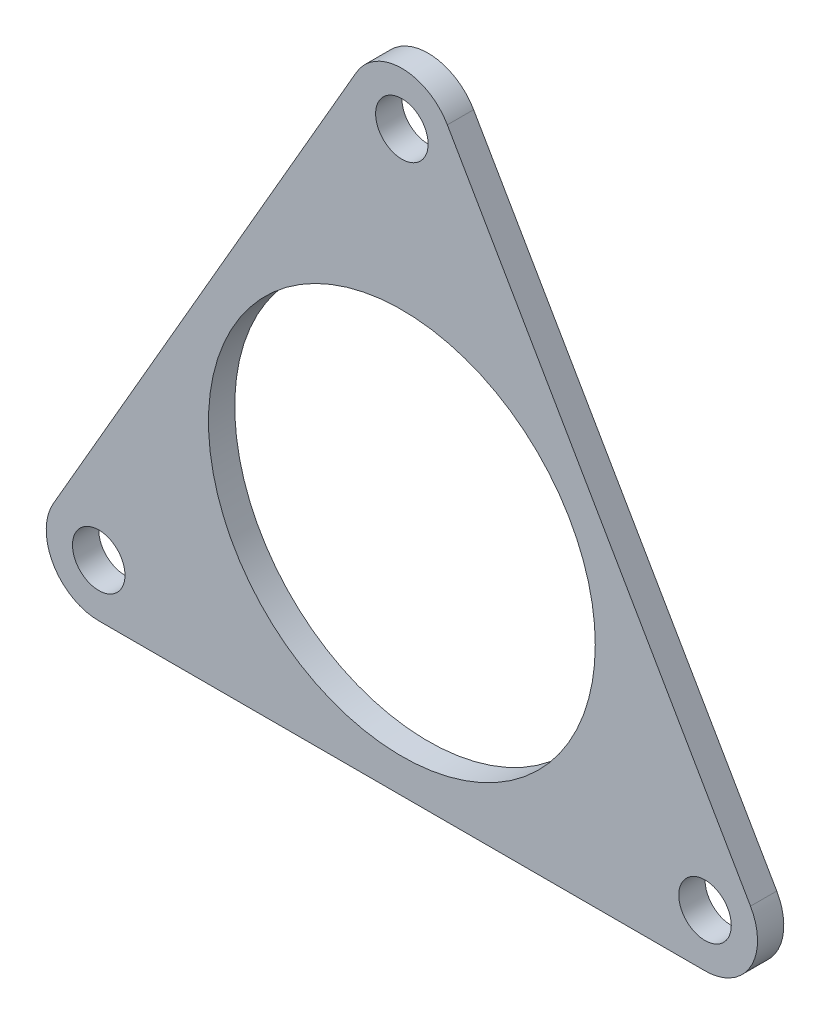
from build123d import *

# Parameters (mm, degrees)
SKETCH_1_R      = 1.5
SKETCH_1_R_2    = 11.05
EXTRUDE_1_DEPTH = 1.5


with BuildPart() as part:
    # 草图1 → 凸台-拉伸1 (new body)
    with BuildSketch(Plane.XY):
        with BuildLine():
            Line((-2.598076211, 21.5), (-19.918584287, -8.5))
            ThreePointArc((-19.918584287, -8.5), (-19.918584287, -11.5), (-17.320508076, -13))
            Line((-17.320508076, -13), (17.320508076, -13))
            ThreePointArc((17.320508076, -13), (19.918584287, -11.5), (19.918584287, -8.5))
            Line((19.918584287, -8.5), (2.598076211, 21.5))
            ThreePointArc((2.598076211, 21.5), (0, 23), (-2.598076211, 21.5))
        make_face()
        with Locations((-17.320508076, -10)):
            Circle(SKETCH_1_R, mode=Mode.SUBTRACT)
        with Locations((0, 20)):
            Circle(SKETCH_1_R, mode=Mode.SUBTRACT)
        with Locations((17.320508076, -10)):
            Circle(SKETCH_1_R, mode=Mode.SUBTRACT)
        Circle(SKETCH_1_R_2, mode=Mode.SUBTRACT)
    extrude(amount=EXTRUDE_1_DEPTH)


solid = part.part
